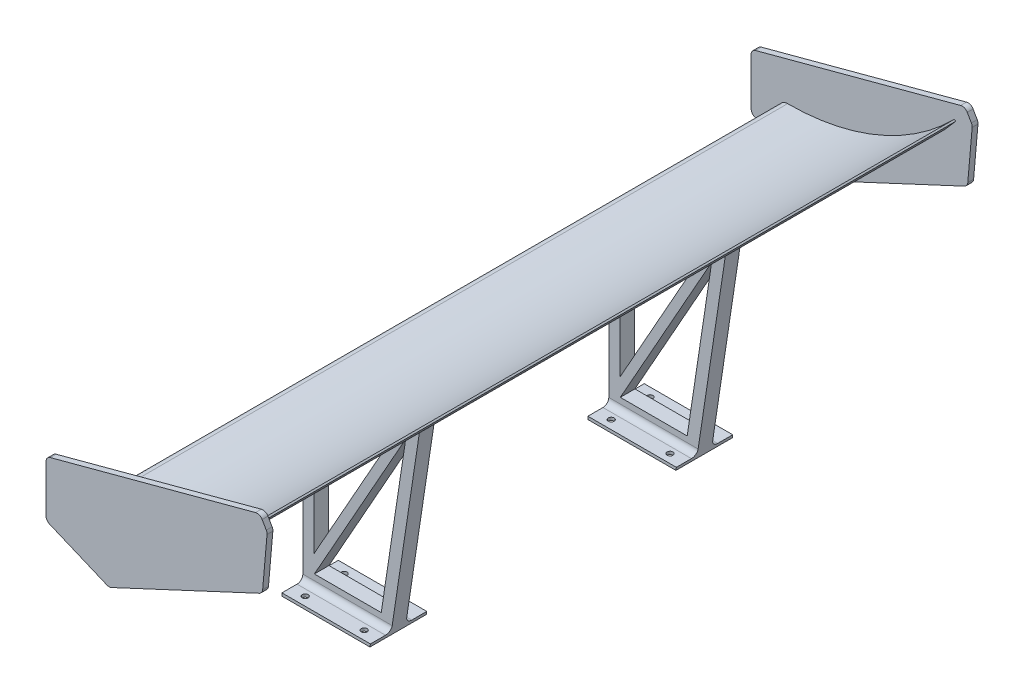
from build123d import *

# Parameters (mm, degrees)
BOSS_EXTRUDE1_DEPTH             = 600
BOSS_EXTRUDE2_DEPTH             = 10
FILLET1_R                       = 10
FILLET1_OF_MIRROR2_R            = 10
BOSS_EXTRUDE3_REACH             = 718.356
SKETCH3_W                       = 200
SKETCH3_H                       = 25
BOSS_EXTRUDE3_DIRECTION_2_DEPTH = 220
SKETCH4_W                       = 200
SKETCH4_H                       = 96.738577366
BOSS_EXTRUDE4_DEPTH             = 5
FILLET3_R                       = 10
SKETCH5_R                       = 5
CUT_EXTRUDE1_DEPTH              = 5
CUT_EXTRUDE3_REACH              = 731.903
CUT_EXTRUDE3_DIRECTION_2_REACH  = 731.903


with BuildPart() as part:
    # Sketch1 → Boss-Extrude1 (new, symmetric)
    with BuildSketch(Plane.XY):
        with BuildLine():
            Line((301.229416671, 150), (303.350737014, 147.878679656))
            ThreePointArc((303.350737014, 147.878679656), (175.223022732, 43.605710521), (15.886569686, 0))
            ThreePointArc((15.886569686, 0), (0.006557212, 14.530298176), (15, 29.973776885))
            ThreePointArc((15, 29.973776885), (170.230890365, 61.093138188), (301.229416671, 150))
        make_face()
    extrude(amount=BOSS_EXTRUDE1_DEPTH, both=True)

    # Sketch2 → Boss-Extrude2 (add)
    with BuildSketch(Plane.XY.offset(600)):
        Polygon((-47.601621627, 79.452155227), (-47.601621627, -15.547844773), (60.841138561, -61.045034952), (323.670396802, 61.514260953), (331.950192363, 156.152757271), (319.450192363, 177.803392366), align=None)
    boss_extrude2 = extrude(amount=BOSS_EXTRUDE2_DEPTH)

    # Fillet1
    fillet1_edges = [part.edges().sort_by_distance(p)[0] for p in [
        (319.450192363, 177.803392366, 605),
        (-47.601621627, 79.452155227, 605),
        (-47.601621627, -15.547844773, 605),
        (60.841138561, -61.045034952, 605),
        (323.670396802, 61.514260953, 605),
        (331.950192363, 156.152757271, 605),
    ]]
    fillet(fillet1_edges, radius=FILLET1_R)

    # Mirror2: Boss-Extrude2 across plane
    add(boss_extrude2.mirror(Plane.XY))

    # Fillet1 of Mirror2
    fillet1_of_mirror2_edges = [part.edges().sort_by_distance(p)[0] for p in [
        (319.450192363, 177.803392366, -605),
        (-47.601621627, 79.452155227, -605),
        (-47.601621627, -15.547844773, -605),
        (60.841138561, -61.045034952, -605),
        (323.670396802, 61.514260953, -605),
        (331.950192363, 156.152757271, -605),
    ]]
    fillet(fillet1_of_mirror2_edges, radius=FILLET1_OF_MIRROR2_R)

    # Sketch3 → Boss-Extrude3 (add, up to next)
    with BuildSketch(Plane(origin=(0, 0, 0), x_dir=(1, 0, 0), z_dir=(0, 1, 0)), mode=Mode.PRIVATE) as boss_extrude3_sk1:
        with Locations((158.114708335, -262.5)):
            Rectangle(SKETCH3_W, SKETCH3_H)
    boss_extrude3_tool1 = extrude(boss_extrude3_sk1.sketch, amount=BOSS_EXTRUDE3_REACH, mode=Mode.PRIVATE) - part.part
    boss_extrude3 = boss_extrude3_tool1.solids().sort_by_distance((158.114708, 0, 262.5))[0]
    add(boss_extrude3)

    # Sketch3 → Boss-Extrude3 direction 2 (add)
    with BuildSketch(Plane(origin=(0, 0, 0), x_dir=(1, 0, 0), z_dir=(0, 1, 0))):
        with Locations((158.114708335, -262.5)):
            Rectangle(SKETCH3_W, SKETCH3_H)
    boss_extrude3_direction_2 = extrude(amount=-BOSS_EXTRUDE3_DIRECTION_2_DEPTH)

    # Mirror3: Boss-Extrude3, Boss-Extrude3 direction 2 across plane
    add(boss_extrude3.mirror(Plane.XY))
    add(boss_extrude3_direction_2.mirror(Plane.XY))

    # Sketch4 → Boss-Extrude4 (add)
    with BuildSketch(Plane.XZ.offset(220)):
        with Locations((158.114708335, 262.5)):
            Rectangle(SKETCH4_W, SKETCH4_H)
    boss_extrude4 = extrude(amount=BOSS_EXTRUDE4_DEPTH)

    # Mirror6: Boss-Extrude4 across plane
    add(boss_extrude4.mirror(Plane.XY))

    # Fillet3
    fillet3_edges = [part.edges().sort_by_distance(p)[0] for p in [
        (158.114708335, -220, 275),
        (158.114708335, -220, 250),
        (158.114708335, -220, -250),
        (158.114708335, -220, -275),
    ]]
    fillet(fillet3_edges, radius=FILLET3_R)

    # Sketch5 → Cut-Extrude1 (cut)
    with BuildSketch(Plane.XZ.offset(225)):
        with Locations(Location((83.114708335, 295.869288683, 0), (0, 0, 270))):
            Circle(SKETCH5_R)
        with Locations(Location((184.214708335, 295.869288683, 0), (0, 0, 270))):
            Circle(SKETCH5_R)
        with Locations(Location((184.214708335, 229.130711317, 0), (0, 0, 270))):
            Circle(SKETCH5_R)
        with Locations(Location((83.114708335, 229.130711317, 0), (0, 0, 270))):
            Circle(SKETCH5_R)
    cut_extrude1 = extrude(amount=-CUT_EXTRUDE1_DEPTH, mode=Mode.SUBTRACT)

    # Mirror7: Cut-Extrude1 across plane
    add(cut_extrude1.mirror(Plane.XY), mode=Mode.SUBTRACT)

    # Sketch8 → Cut-Extrude3 (cut, up to next)
    with BuildSketch(Plane.XY, mode=Mode.PRIVATE) as cut_extrude3_sk1:
        Polygon((258.114708335, 100), (209.210600029, -225), (258.114708335, -225), align=None)
    cut_extrude3_tool1 = extrude(cut_extrude3_sk1.sketch, amount=-CUT_EXTRUDE3_REACH, mode=Mode.PRIVATE) & part.part
    # Sketch8 → Cut-Extrude3 (cut, up to next)
    with BuildSketch(Plane.XY, mode=Mode.PRIVATE) as cut_extrude3_sk2:
        Polygon((192.672505063, -200), (234.626697196, 78.813230948), (77.908149081, -200), align=None)
    cut_extrude3_tool2 = extrude(cut_extrude3_sk2.sketch, amount=-CUT_EXTRUDE3_REACH, mode=Mode.PRIVATE) & part.part
    # Sketch8 → Cut-Extrude3 (cut, up to next)
    with BuildSketch(Plane.XY, mode=Mode.PRIVATE) as cut_extrude3_sk3:
        Polygon((77.406994689, -169.918867637), (203.697901707, 54.761466943), (77.406994689, -7.882832173), align=None)
    cut_extrude3_tool3 = extrude(cut_extrude3_sk3.sketch, amount=-CUT_EXTRUDE3_REACH, mode=Mode.PRIVATE) & part.part
    add(cut_extrude3_tool1.solids().sort_by_distance((241.813339, -116.666667, 0))[0], mode=Mode.SUBTRACT)
    add(cut_extrude3_tool2.solids().sort_by_distance((168.40245, -107.062256, 0))[0], mode=Mode.SUBTRACT)
    add(cut_extrude3_tool3.solids().sort_by_distance((119.503964, -41.013411, 0))[0], mode=Mode.SUBTRACT)

    # Sketch8 → Cut-Extrude3 direction 2 (cut, up to next)
    with BuildSketch(Plane.XY, mode=Mode.PRIVATE) as cut_extrude3_direction_2_sk1:
        Polygon((258.114708335, 100), (209.210600029, -225), (258.114708335, -225), align=None)
    cut_extrude3_direction_2_tool1 = extrude(cut_extrude3_direction_2_sk1.sketch, amount=CUT_EXTRUDE3_DIRECTION_2_REACH, mode=Mode.PRIVATE) & part.part
    # Sketch8 → Cut-Extrude3 direction 2 (cut, up to next)
    with BuildSketch(Plane.XY, mode=Mode.PRIVATE) as cut_extrude3_direction_2_sk2:
        Polygon((192.672505063, -200), (234.626697196, 78.813230948), (77.908149081, -200), align=None)
    cut_extrude3_direction_2_tool2 = extrude(cut_extrude3_direction_2_sk2.sketch, amount=CUT_EXTRUDE3_DIRECTION_2_REACH, mode=Mode.PRIVATE) & part.part
    # Sketch8 → Cut-Extrude3 direction 2 (cut, up to next)
    with BuildSketch(Plane.XY, mode=Mode.PRIVATE) as cut_extrude3_direction_2_sk3:
        Polygon((77.406994689, -169.918867637), (203.697901707, 54.761466943), (77.406994689, -7.882832173), align=None)
    cut_extrude3_direction_2_tool3 = extrude(cut_extrude3_direction_2_sk3.sketch, amount=CUT_EXTRUDE3_DIRECTION_2_REACH, mode=Mode.PRIVATE) & part.part
    add(cut_extrude3_direction_2_tool1.solids().sort_by_distance((241.813339, -116.666667, 0))[0], mode=Mode.SUBTRACT)
    add(cut_extrude3_direction_2_tool2.solids().sort_by_distance((168.40245, -107.062256, 0))[0], mode=Mode.SUBTRACT)
    add(cut_extrude3_direction_2_tool3.solids().sort_by_distance((119.503964, -41.013411, 0))[0], mode=Mode.SUBTRACT)


solid = part.part
